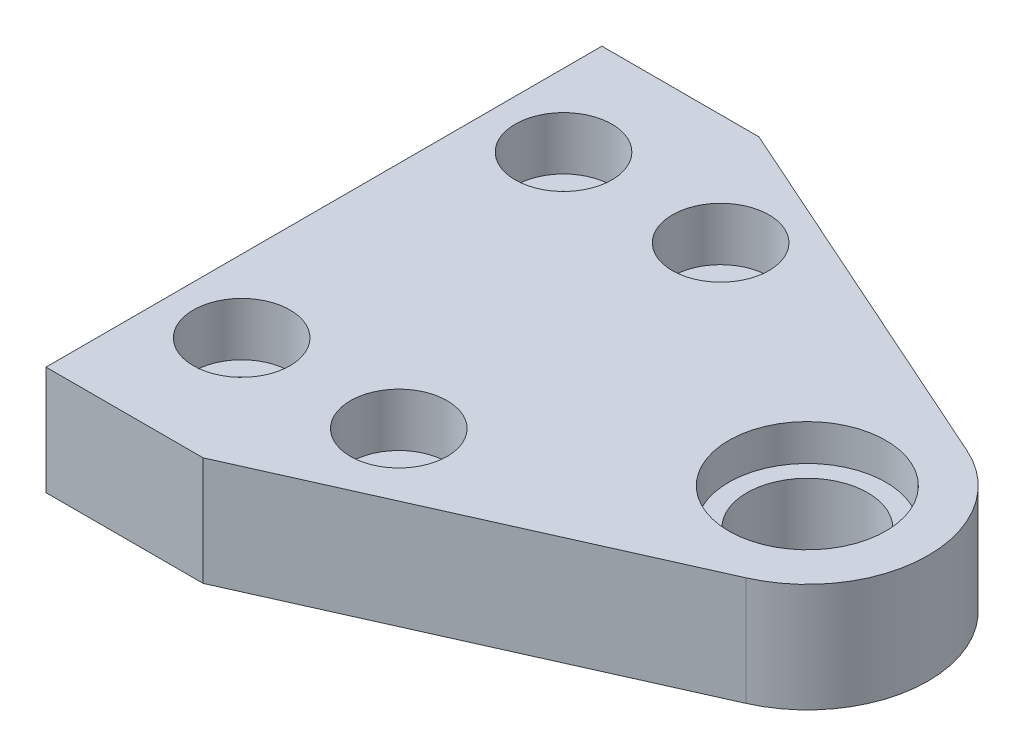
from build123d import *

# Parameters (mm, degrees)
EXTRUDE_1_DEPTH              = 9
SKETCH_2_W                   = 24
SKETCH_2_H                   = 10
EXTRUDE_2_DEPTH              = 3
HOLE_WIZARD_M4_1_D           = 4.5
HOLE_WIZARD_M4_1_DEPTH       = 9
HOLE_WIZARD_M4_1_CBORE_D     = 8
HOLE_WIZARD_M4_1_CBORE_DEPTH = 4.4
HOLE_WIZARD_M4_1_TIP         = 1.351936393
HOLE_WIZARD_M4_2_D           = 10
HOLE_WIZARD_M4_2_CBORE_D     = 13
HOLE_WIZARD_M4_2_CBORE_DEPTH = 3


with BuildPart() as part:
    # 스케치1 → 보스-돌출1 (new body)
    with BuildSketch(Plane(origin=(0, 0, 0), x_dir=(1, 0, 0), z_dir=(0, 1, 0))):
        with BuildLine():
            Line((0, 0), (0, 23))
            Line((0, 23), (13, 23))
            Line((13, 23), (44.075327331, 9.131905997))
            ThreePointArc((44.075327331, 9.131905997), (50, 0), (44.075327331, -9.131905997))
            Line((44.075327331, -9.131905997), (13, -23))
            Line((13, -23), (0, -23))
            Line((0, -23), (0, 0))
        make_face()
    extrude(amount=EXTRUDE_1_DEPTH)

    # 스케치2 → 보스-돌출2 (add)
    with BuildSketch(Plane.XZ):
        with Locations((12, 0)):
            Rectangle(SKETCH_2_W, SKETCH_2_H)
    extrude(amount=EXTRUDE_2_DEPTH)

    # M4 소켓 머리 캡 나사용 카운터보어1
    with Locations(Plane(origin=(0, 9, 0), x_dir=(1, 0, 0), z_dir=(0, 1, 0))):
        with Locations((6, 13.827116768), (19, 13.827116768), (6, -12.807083564), (19, -12.807083564)):
            CounterBoreHole(HOLE_WIZARD_M4_1_D / 2, HOLE_WIZARD_M4_1_CBORE_D / 2, HOLE_WIZARD_M4_1_CBORE_DEPTH, depth=HOLE_WIZARD_M4_1_DEPTH)
            with Locations((0, 0, -(HOLE_WIZARD_M4_1_DEPTH + HOLE_WIZARD_M4_1_TIP / 2))):  # 118° drill point
                Cone(0, HOLE_WIZARD_M4_1_D / 2, HOLE_WIZARD_M4_1_TIP, mode=Mode.SUBTRACT)

    # M4 소켓 머리 캡 나사용 카운터보어2 (through all)
    with Locations(Plane(origin=(0, 9, 0), x_dir=(1, 0, 0), z_dir=(0, 1, 0))):
        with Locations((40, 0)):
            CounterBoreHole(HOLE_WIZARD_M4_2_D / 2, HOLE_WIZARD_M4_2_CBORE_D / 2, HOLE_WIZARD_M4_2_CBORE_DEPTH)


solid = part.part
